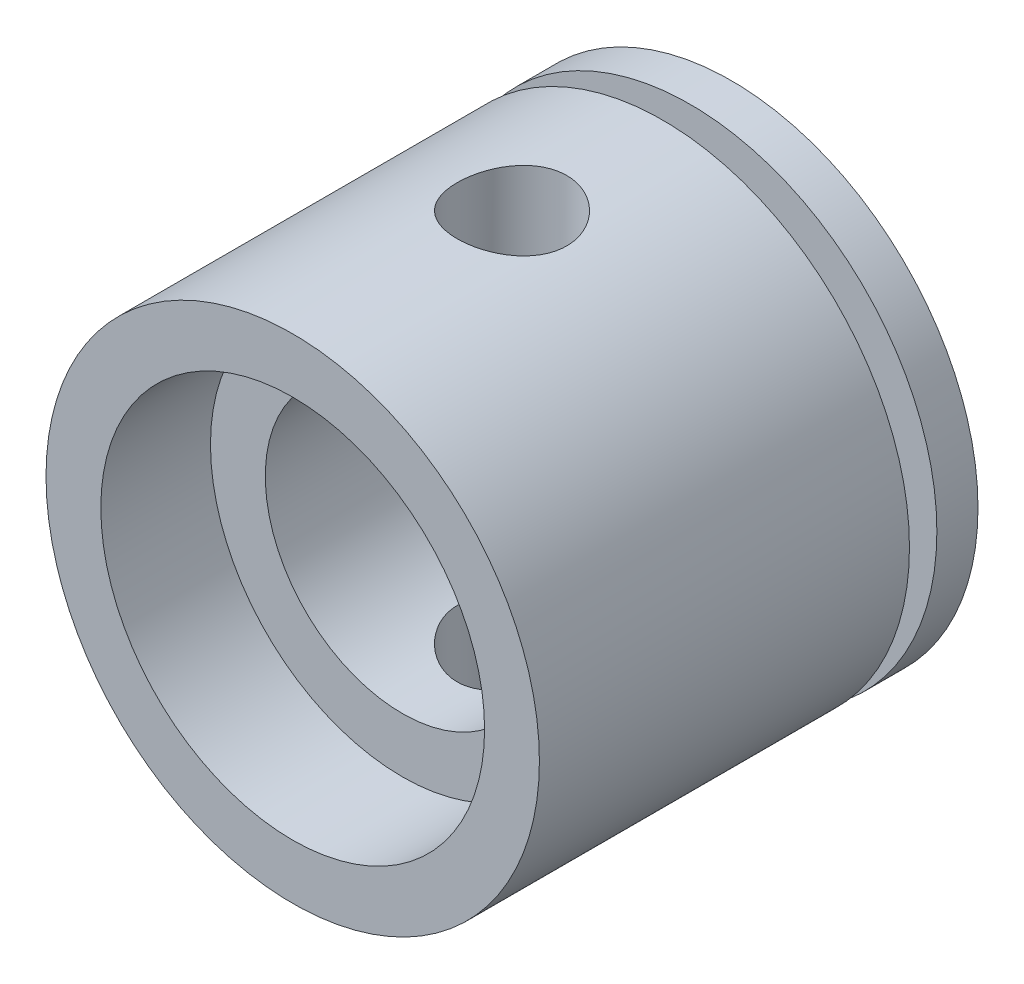
from build123d import *

# Parameters (mm, degrees)
SKETCH1_R                                = 9
BOSS_EXTRUDE1_DEPTH                      = 16
CBORE_FOR_M14_HEX_HEAD_BOLT1_D           = 10
CBORE_FOR_M14_HEX_HEAD_BOLT1_DEPTH       = 14
CBORE_FOR_M14_HEX_HEAD_BOLT1_CBORE_D     = 14
CBORE_FOR_M14_HEX_HEAD_BOLT1_CBORE_DEPTH = 4
SKETCH4_R                                = 9
SKETCH4_R_2                              = 7.5
CUT_EXTRUDE1_DEPTH                       = 1
SKETCH5_R                                = 2
CUT_EXTRUDE2_DEPTH                       = 15.5


with BuildPart() as part:
    # Sketch1 → Boss-Extrude1 (new body)
    with BuildSketch(Plane.XY):
        Circle(SKETCH1_R)
    extrude(amount=BOSS_EXTRUDE1_DEPTH)

    # CBORE for M14 Hex Head Bolt1
    with Locations(Plane.XY.offset(16)):
        with Locations((0, 0)):
            CounterBoreHole(CBORE_FOR_M14_HEX_HEAD_BOLT1_D / 2, CBORE_FOR_M14_HEX_HEAD_BOLT1_CBORE_D / 2, CBORE_FOR_M14_HEX_HEAD_BOLT1_CBORE_DEPTH, depth=CBORE_FOR_M14_HEX_HEAD_BOLT1_DEPTH)

    # Sketch4 → Cut-Extrude1 (cut)
    with BuildSketch(Plane.XY.offset(2.5)):
        Circle(SKETCH4_R)
        Circle(SKETCH4_R_2, mode=Mode.SUBTRACT)
    extrude(amount=-CUT_EXTRUDE1_DEPTH, mode=Mode.SUBTRACT)

    # Sketch5 → Cut-Extrude2 (cut, symmetric)
    with BuildSketch(Plane(origin=(0, 0, 0), x_dir=(1, 0, 0), z_dir=(0, 1, 0))):
        with Locations(Location((0, -8, 0), (0, 0, 270))):  # turned: the seam where the file's is
            Circle(SKETCH5_R)
    extrude(amount=CUT_EXTRUDE2_DEPTH, both=True, mode=Mode.SUBTRACT)


solid = part.part
